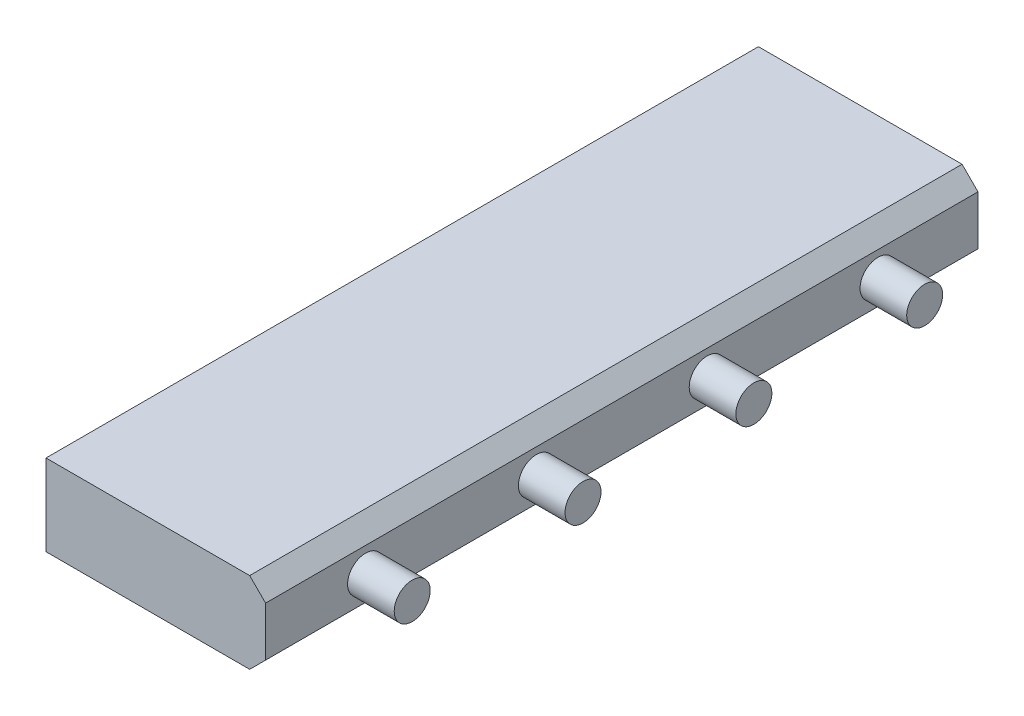
from build123d import *

# Parameters (mm, degrees)
BOSS_EXTRUDE1_DEPTH = 2.138
SKETCH2_R           = 0.0540073
BOSS_EXTRUDE2_DEPTH = 0.14


with BuildPart() as part:
    # Sketch1 → Boss-Extrude1 (new body)
    with BuildSketch(Plane.XY):
        Polygon((0, 0), (0.61123, 0), (0.659, 0.04777), (0.659, 0.19598), (0.61123, 0.24375), (0, 0.24375), align=None)
    extrude(amount=BOSS_EXTRUDE1_DEPTH)

    # Sketch2 → Boss-Extrude2 (add)
    with BuildSketch(Plane(origin=(0.659, 0, 0), x_dir=(0, 0, -1), z_dir=(1, 0, 0))):
        with Locations((-1.838, 0.121875)):
            Circle(SKETCH2_R)
        with Locations((-1.325333333, 0.121875)):
            Circle(SKETCH2_R)
        with Locations((-0.812666667, 0.121875)):
            Circle(SKETCH2_R)
        with Locations((-0.3, 0.121875)):
            Circle(SKETCH2_R)
    extrude(amount=BOSS_EXTRUDE2_DEPTH)


solid = part.part
